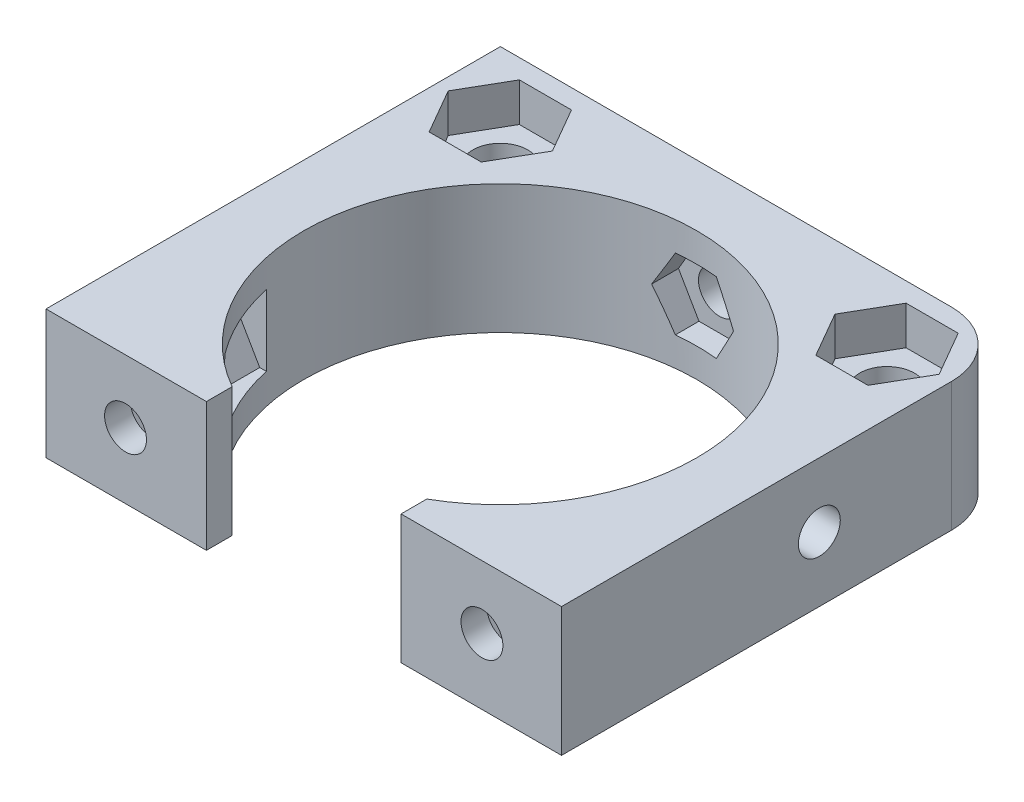
from build123d import *

# Parameters (mm, degrees)
CROQUIS1_R                              = 15.25
CROQUIS1_R_2                            = 2.125
SOPORTE_CAJA_REDUCTORA_DEPTH            = 20
CROQUIS3_R                              = 2.125
CORTAR_EXTRUIR1_DEPTH                   = 51.423828692
REDONDEO1_R                             = 5
BOSS_EXTRUDE1_DEPTH                     = 20
CUT_EXTRUDE1_REACH                      = 55.852
SKETCH2_R                               = 1.625
CUT_EXTRUDE2_DEPTH                      = 2
SKETCH4_R                               = 1.625
CUT_EXTRUDE3_DEPTH                      = 63.291652731
CUT_EXTRUDE4_START                      = -4.5
CUT_EXTRUDE4_DEPTH                      = 2
CROQUIS6_W                              = 4.75
CROQUIS6_H                              = 4.75
CORTAR_EXTRUIR17_DEPTH                  = 42.231056256
CROQUIS7_W                              = 60
CROQUIS7_H                              = 20
CORTAR_EXTRUIR18_DEPTH                  = 51.423828692
SALIENTE_EXTRUIR2_DEPTH                 = 49
SOPORTE_START                           = -15
SOPORTE_MOTOR_DEPTH                     = 15
CROQUIS12_R                             = 2.125
AGUJEROS_DE_SUJECION_A_BASE_DEPTH       = 84.087679592
TUERCA_START                            = -4
TUERCA_AGUJERO_DE_SUJECION_A_BASE_DEPTH = 10
SALIENTE_EXTRUIR4_DEPTH                 = 15
CORTAR_EXTRUIR19_DEPTH                  = 25
CROQUIS14_W                             = 50
CROQUIS14_H                             = 118
CORTAR_EXTRUIR22_DEPTH                  = 146.556045907
CROQUIS15_W                             = 10
CROQUIS15_H                             = 7
CORTAR_EXTRUIR23_DEPTH                  = 42.231056256
CORTAR_EXTRUIR24_DEPTH                  = 42.231056256
CROQUIS18_W                             = 40
CROQUIS18_H                             = 10
CORTAR_EXTRUIR25_DEPTH                  = 44.27311521
SALIENTE_EXTRUIR5_DEPTH                 = 10
CROQUIS20_R                             = 1
CORTAR_EXTRUIR26_DEPTH                  = 49.229270158
CORTAR_EXTRUIR27_REACH                  = 62.959
CORTAR_EXTRUIR27_END_RADIUS             = 15.25
CROQUIS21_R                             = 1.625
CROQUIS22_R                             = 2.125
CROQUIS22_R_2                           = 1
SALIENTE_EXTRUIR6_DEPTH                 = 10
CROQUIS23_R                             = 1.625
CORTAR_EXTRUIR28_DEPTH                  = 52.269508521
CORTAR_EXTRUIR29_START                  = -3
CORTAR_EXTRUIR29_DEPTH                  = 10
SALIENTE_EXTRUIR7_DEPTH                 = 10
CORTAR_EXTRUIR30_REACH                  = 72.235
CROQUIS27_R                             = 1.625
CORTAR_EXTRUIR31_REACH                  = 75.235
CORTAR_EXTRUIR31_START                  = -3
CORTAR_EXTRUIR32_REACH                  = 58.612
CROQUIS29_R                             = 1.625
CORTAR_EXTRUIR33_REACH                  = 61.112
CORTAR_EXTRUIR33_START                  = -2.5
CROQUIS35_W                             = 13.305418987
CROQUIS35_H                             = 6.826864192
CORTAR_EXTRUIR34_DEPTH                  = 63.931555098
CORTAR_EXTRUIR34_DEPTH_BACK             = 63.931555098
CORTAR_EXTRUIR35_START                  = -3
CORTAR_EXTRUIR35_DEPTH                  = 10
SALIENTE_EXTRUIR8_DEPTH                 = 10
SALIENTE_EXTRUIR9_DEPTH                 = 13
SALIENTE_EXTRUIR10_DEPTH                = 3
CROQUIS40_W                             = 106.583537839
CROQUIS40_H                             = 47.391515964
CORTAR_EXTRUIR36_DEPTH                  = 80.887064817
CORTAR_EXTRUIR36_DEPTH_BACK             = 80.887064817
CORTAR_EXTRUIR37_DEPTH                  = 67.2524009
CORTAR_EXTRUIR37_DEPTH_BACK             = 67.2524009
CORTAR_EXTRUIR38_DEPTH                  = 79.704784639
CORTAR_EXTRUIR38_DEPTH_BACK             = 79.704784639
SALIENTE_EXTRUIR11_DEPTH                = 10
CORTAR_EXTRUIR39_DEPTH                  = 63.9908649
CROQUIS45_W                             = 31.470301378
CROQUIS45_H                             = 10
CROQUIS45_R                             = 1.625
SALIENTE_EXTRUIR12_DEPTH                = 2.5
SALIENTE_EXTRUIR13_DEPTH                = 10
CORTAR_EXTRUIR40_START                  = -2
CROQUIS47_R                             = 1.625
CORTAR_EXTRUIR40_DEPTH                  = 10
CORTAR_EXTRUIR41_START                  = -12
CROQUIS48_R                             = 1.625
CORTAR_EXTRUIR41_DEPTH                  = 12
CORTAR_EXTRUIR42_DEPTH                  = 3
CROQUIS50_R                             = 2.125
CORTAR_EXTRUIR43_DEPTH                  = 52.795622989
CORTAR_EXTRUIR43_DEPTH_BACK             = 52.795622989
CORTAR_EXTRUIR44_DEPTH                  = 52.795622989
CORTAR_EXTRUIR44_DEPTH_BACK             = 52.795622989
SALIENTE_EXTRUIR14_DEPTH                = 10
CORTAR_EXTRUIR45_START                  = -24.591895
CORTAR_EXTRUIR45_DEPTH                  = 17.091895
CROQUIS55_W                             = 28.124395824
CROQUIS55_H                             = 43.73373215
CORTAR_EXTRUIR46_DEPTH                  = 42.681058385
CORTAR_EXTRUIR46_DEPTH_BACK             = 42.681058385


with BuildPart() as part:
    # Croquis1 → Soporte caja reductora (new body)
    with BuildSketch(Plane(origin=(0, 0, 0), x_dir=(1, 0, 0), z_dir=(0, 1, 0))):
        Polygon((-30, -15.25), (-20, -15.25), (-20, -20), (20, -20), (20, -15.25), (30, -15.25), (30, -7.25), (20, -4.25), (20, 20), (-20, 20), (-20, -4.25), (-30, -7.25), align=None)
        with Locations(Location((0, 0, 0), (0, 0, 270))):
            Circle(CROQUIS1_R, mode=Mode.SUBTRACT)
        with Locations(Location((-15, 15, 0), (0, 0, 270))):
            Circle(CROQUIS1_R_2, mode=Mode.SUBTRACT)
        with Locations(Location((15, 15, 0), (0, 0, 270))):
            Circle(CROQUIS1_R_2, mode=Mode.SUBTRACT)
    extrude(amount=-SOPORTE_CAJA_REDUCTORA_DEPTH)

    # Croquis3 → Cortar-Extruir1 (cut, through all)
    with BuildSketch(Plane.XY.offset(15.25)):
        with Locations((-23.5, -10)):
            Circle(CROQUIS3_R)
        with Locations((23.5, -10)):
            Circle(CROQUIS3_R)
    extrude(amount=-CORTAR_EXTRUIR1_DEPTH, mode=Mode.SUBTRACT)

    # Redondeo1
    redondeo1_edges = [part.edges().sort_by_distance(p)[0] for p in [
        (-20, -10, -20),
        (20, -10, -20),
    ]]
    fillet(redondeo1_edges, radius=REDONDEO1_R)

    # Sketch1 → Boss-Extrude1 (add)
    with BuildSketch(Plane(origin=(0, 0, 0), x_dir=(1, 0, 0), z_dir=(0, 1, 0))):
        with BuildLine():
            Line((25.5, 15), (20, 15))
            ThreePointArc((20, 15), (18.535533906, 18.535533906), (15, 20))
            Line((15, 20), (30, 20))
            Line((30, 20), (30, 8))
            Line((30, 8), (25.5, 8))
            Line((25.5, 8), (25.5, 15))
        make_face()
    extrude(amount=-BOSS_EXTRUDE1_DEPTH)

    # Sketch2 → Cut-Extrude1 (cut, up to next)
    with BuildSketch(Plane(origin=(0, 0, -20), x_dir=(-1, 0, 0), z_dir=(0, 0, -1)), mode=Mode.PRIVATE) as cut_extrude1_sk1:
        with Locations((-22.75, -10)):
            Circle(SKETCH2_R)
    cut_extrude1_tool1 = extrude(cut_extrude1_sk1.sketch, amount=-CUT_EXTRUDE1_REACH, mode=Mode.PRIVATE) & part.part
    add(cut_extrude1_tool1.solids().sort_by_distance((22.75, -10, -20))[0], mode=Mode.SUBTRACT)

    # Sketch3 → Cut-Extrude2 (cut)
    with BuildSketch(Plane.XY.offset(-15)):
        Polygon((20, -11.58771324), (22.75, -13.175426481), (25.5, -11.58771324), (25.5, -8.41228676), (22.75, -6.824573519), (20, -8.41228676), align=None)
    extrude(amount=-CUT_EXTRUDE2_DEPTH, mode=Mode.SUBTRACT)

    # Sketch4 → Cut-Extrude3 (cut, through all)
    with BuildSketch(Plane.ZY.offset(-25.5)):
        with Locations((-12.25, -10)):
            Circle(SKETCH4_R)
    extrude(amount=-CUT_EXTRUDE3_DEPTH, mode=Mode.SUBTRACT)

    # Sketch5 → Cut-Extrude4 (cut)
    with BuildSketch(Plane(origin=(30, 0, 0), x_dir=(0, 0, -1), z_dir=(1, 0, 0)).offset(CUT_EXTRUDE4_START)):
        Polygon((15, -11.58771324), (15, -8.41228676), (12.25, -6.824573519), (9.5, -8.41228676), (9.5, -11.58771324), (12.25, -13.175426481), align=None)
    extrude(amount=CUT_EXTRUDE4_DEPTH, mode=Mode.SUBTRACT)

    # Croquis6 → Cortar-Extruir17 (cut, through all)
    with BuildSketch(Plane(origin=(0, 0, 0), x_dir=(1, 0, 0), z_dir=(0, 1, 0))):
        Polygon((0, -15.25), (-15.25, -15.25), (-15.25, -20), (15.25, -20), (15.25, -15.25), align=None)
        with Locations((-17.625, -17.625)):
            Rectangle(CROQUIS6_W, CROQUIS6_H)
        with BuildLine():
            ThreePointArc((0, -15.25), (-10.783378413, -10.783378413), (-15.25, 0))
            Line((-15.25, 0), (-15.25, -15.25))
            Line((-15.25, -15.25), (0, -15.25))
        make_face()
        with BuildLine():
            Line((15.25, -15.25), (15.25, 0))
            ThreePointArc((15.25, 0), (10.783378413, -10.783378413), (0, -15.25))
            Line((0, -15.25), (15.25, -15.25))
        make_face()
        with Locations((17.625, -17.625)):
            Rectangle(CROQUIS6_W, CROQUIS6_H)
    extrude(amount=-CORTAR_EXTRUIR17_DEPTH, mode=Mode.SUBTRACT)


with BuildPart() as body_2:
    # Simetría1: mirrored copy
    add(part.part.mirror(Plane.ZX))

    # Croquis8 → Saliente-Extruir2 (add)
    with BuildSketch(Plane(origin=(0, 20, 0), x_dir=(1, 0, 0), z_dir=(0, 1, 0))):
        with BuildLine():
            Line((-12.664515522, 20), (-11.040489496, 13.939052358))
            Line((-11.040489496, 13.939052358), (-10.315162126, 11.232093763))
            ThreePointArc((-10.315162126, 11.232093763), (0, 15.25), (10.315162126, 11.232093763))
            Line((10.315162126, 11.232093763), (10.817418481, 13.87928066))
            Line((10.817418481, 13.87928066), (11.978715476, 20))
            Line((11.978715476, 20), (-12.664515522, 20))
        make_face()
    extrude(amount=SALIENTE_EXTRUIR2_DEPTH)

    # Croquis9 → Soporte motor (add)
    with BuildSketch(Plane(origin=(0, 69, 0), x_dir=(1, 0, 0), z_dir=(0, 1, 0)).offset(SOPORTE_START)):
        with BuildLine():
            Line((-20, 15), (-20, -4.25))
            Line((-20, -4.25), (-30, -7.25))
            Line((-30, -7.25), (-30, -15.25))
            Line((-30, -15.25), (0, -15.25))
            Line((0, -15.25), (0, -14.75))
            ThreePointArc((0, -14.75), (-10.429825023, 10.429825023), (14.75, 0))
            Line((14.75, 0), (20, 0))
            Line((20, 0), (20, 13.936837101))
            Line((20, 13.936837101), (12.664515522, 20))
            Line((12.664515522, 20), (-15, 20))
            ThreePointArc((-15, 20), (-18.535533906, 18.535533906), (-20, 15))
        make_face()
    extrude(amount=-SOPORTE_MOTOR_DEPTH)

    # Croquis12 → Agujeros de sujecion a base (cut, through all)
    with BuildSketch(Plane.XY.offset(15.25)):
        with Locations((-23.5, 46.5)):
            Circle(CROQUIS12_R)
    extrude(amount=-AGUJEROS_DE_SUJECION_A_BASE_DEPTH, mode=Mode.SUBTRACT)

    # Croquis13 → Tuerca Agujero de sujecion a base (cut)
    with BuildSketch(Plane.XY.offset(15.25).offset(TUERCA_START)):
        Polygon((-20, 44.479274058), (-20, 48.520725942), (-23.5, 50.541451884), (-27, 48.520725942), (-27, 44.479274058), (-23.5, 42.458548116), align=None)
    extrude(amount=-TUERCA_AGUJERO_DE_SUJECION_A_BASE_DEPTH, mode=Mode.SUBTRACT)

    # Croquis10 → Saliente-Extruir4 (add)
    with BuildSketch(Plane(origin=(0, 69, 0), x_dir=(1, 0, 0), z_dir=(0, 1, 0))):
        with BuildLine():
            ThreePointArc((10.315162126, 11.232093763), (0, 15.25), (-10.315162126, 11.232093763))
            Line((-10.315162126, 11.232093763), (-10.16850369, 10.684757026))
            ThreePointArc((-10.16850369, 10.684757026), (0, 14.75), (10.16850369, 10.684757026))
            Line((10.16850369, 10.684757026), (10.315162126, 11.232093763))
        make_face()
    extrude(amount=-SALIENTE_EXTRUIR4_DEPTH)

    # Croquis11 → Cortar-Extruir19 (cut)
    with BuildSketch(Plane.XZ):
        with BuildLine():
            Line((15.25, 4.25), (20, 4.25))
            Line((20, 4.25), (21.972856468, 4.84185694))
            ThreePointArc((21.972856468, 4.84185694), (19.948931102, 10.40625523), (16.543503257, 15.25))
            Line((16.543503257, 15.25), (15.25, 15.25))
            Line((15.25, 15.25), (15.25, 4.25))
        make_face()
        with BuildLine():
            Line((21.972856468, 4.84185694), (30, 7.25))
            Line((30, 7.25), (30, 15.25))
            Line((30, 15.25), (16.543503257, 15.25))
            ThreePointArc((16.543503257, 15.25), (19.948931102, 10.40625523), (21.972856468, 4.84185694))
        make_face()
        with BuildLine():
            ThreePointArc((20, -15), (18.535533906, -18.535533906), (15, -20))
            Line((15, -20), (30, -20))
            Line((30, -20), (30, -8))
            Line((30, -8), (25.5, -8))
            Line((25.5, -8), (25.5, -15))
            Line((25.5, -15), (20, -15))
        make_face()
    extrude(amount=-CORTAR_EXTRUIR19_DEPTH, mode=Mode.SUBTRACT)

    # Simetría2: body 2 across face


with BuildPart() as part_1:
    add(part.part)

    # Croquis7 → Cortar-Extruir18 (cut, through all)
    with BuildSketch(Plane(origin=(0, 0, -20), x_dir=(-1, 0, 0), z_dir=(0, 0, -1))):
        with Locations((0, -10)):
            Rectangle(CROQUIS7_W, CROQUIS7_H)
    extrude(amount=-CORTAR_EXTRUIR18_DEPTH, mode=Mode.SUBTRACT)


with BuildPart() as body_2_1:
    add(body_2.part)
    add(body_2.part.mirror(Plane(origin=(-0.229209569, 69, -16.663998028), x_dir=(0, 0, 1), z_dir=(0, 1, 0))))

    # Croquis14 → Cortar-Extruir22 (cut, through all)
    with BuildSketch(Plane.XY.offset(15.25)):
        with Locations((-5, 79)):
            Rectangle(CROQUIS14_W, CROQUIS14_H)
    extrude(amount=-CORTAR_EXTRUIR22_DEPTH, mode=Mode.SUBTRACT)

    # Croquis15 → Cortar-Extruir23 (cut, through all)
    with BuildSketch(Plane.XZ):
        with Locations((-25, 7.75)):
            Rectangle(CROQUIS15_W, CROQUIS15_H)
    extrude(amount=-CORTAR_EXTRUIR23_DEPTH, mode=Mode.SUBTRACT)

    # Croquis16 → Cortar-Extruir24 (cut, through all)
    with BuildSketch(Plane.XZ):
        Polygon((-30, 15.25), (-15.25, 15.25), (-15.25, 12.75), (-20, 12.75), (-20, 11.25), (-30, 11.25), (-30, 12.75), align=None)
    extrude(amount=-CORTAR_EXTRUIR24_DEPTH, mode=Mode.SUBTRACT)

    # Croquis18 → Cortar-Extruir25 (cut, through all)
    with BuildSketch(Plane(origin=(0, 0, -20), x_dir=(-1, 0, 0), z_dir=(0, 0, -1))):
        with Locations((0, 5)):
            Rectangle(CROQUIS18_W, CROQUIS18_H)
    extrude(amount=-CORTAR_EXTRUIR25_DEPTH, mode=Mode.SUBTRACT)

    # Croquis19 → Saliente-Extruir5 (add)
    with BuildSketch(Plane(origin=(0, 20, 0), x_dir=(1, 0, 0), z_dir=(0, 1, 0))):
        Polygon((-20, -12.75), (-34, -12.75), (-34, -7.75), (-24, -7.75), (-20, -3.75), align=None)
    extrude(amount=-SALIENTE_EXTRUIR5_DEPTH)

    # Croquis20 → Cortar-Extruir26 (cut, through all)
    with BuildSketch(Plane(origin=(0, 0, 7.75), x_dir=(-1, 0, 0), z_dir=(0, 0, -1))):
        with Locations((29, 15)):
            Circle(CROQUIS20_R)
    extrude(amount=-CORTAR_EXTRUIR26_DEPTH, mode=Mode.SUBTRACT)

    # Cortar-Extruir27: up to this cylinder (the profile starts outside it)
    cortar_extruir27_end = Plane(origin=(0, 15, 0), z_dir=(0, -1, 0)) * Cylinder(CORTAR_EXTRUIR27_END_RADIUS, 157.418, mode=Mode.PRIVATE)
    # Croquis21 → Cortar-Extruir27 (cut, up to the surface)
    with BuildSketch(Plane(origin=(20, 0, 0), x_dir=(0, 0, -1), z_dir=(1, 0, 0)), mode=Mode.PRIVATE) as cortar_extruir27_sk1:
        with Locations((4.75, 15)):
            Circle(CROQUIS21_R)
    cortar_extruir27_tool1 = extrude(cortar_extruir27_sk1.sketch, amount=-CORTAR_EXTRUIR27_REACH, mode=Mode.PRIVATE) - cortar_extruir27_end
    add(cortar_extruir27_tool1.solids().sort_by_distance((20, 15, -4.75))[0], mode=Mode.SUBTRACT)

    # Croquis22 → Saliente-Extruir6 (add)
    with BuildSketch(Plane.XZ.offset(-10)):
        with Locations((-15, -15)):
            Circle(CROQUIS22_R)
        with Locations(Location((-15, -15, 0), (0, 0, 270))):
            Circle(CROQUIS22_R_2, mode=Mode.SUBTRACT)
        with Locations((15, -15)):
            Circle(CROQUIS22_R)
        with Locations(Location((15, -15, 0), (0, 0, 270))):
            Circle(CROQUIS22_R_2, mode=Mode.SUBTRACT)
    extrude(amount=-SALIENTE_EXTRUIR6_DEPTH)

    # Croquis23 → Cortar-Extruir28 (cut, through all)
    with BuildSketch(Plane(origin=(0, 0, -20), x_dir=(-1, 0, 0), z_dir=(0, 0, -1))):
        with Locations((0, 15)):
            Circle(CROQUIS23_R)
    extrude(amount=-CORTAR_EXTRUIR28_DEPTH, mode=Mode.SUBTRACT)

    # Croquis24 → Cortar-Extruir29 (cut)
    with BuildSketch(Plane(origin=(0, 0, -20), x_dir=(-1, 0, 0), z_dir=(0, 0, -1)).offset(CORTAR_EXTRUIR29_START)):
        Polygon((1.58771324, 12.25), (3.175426481, 15), (1.58771324, 17.75), (-1.58771324, 17.75), (-3.175426481, 15), (-1.58771324, 12.25), align=None)
    extrude(amount=-CORTAR_EXTRUIR29_DEPTH, mode=Mode.SUBTRACT)

    # Croquis26 → Saliente-Extruir7 (add)
    with BuildSketch(Plane.XZ.offset(-10)):
        Polygon((-34, 7.75), (-34, 12.75), (-58.825, 12.75), (-39.160527763, -4.104491148), (-20, -4.104491148), (-20, -0.104491148), (-35.732113118, -0.104491148), (-29, 7.75), align=None)
        Polygon((-34.268209086, 7.75), (-39.594516123, 1.535690951), (-46.844874897, 7.75), align=None, mode=Mode.SUBTRACT)
    extrude(amount=-SALIENTE_EXTRUIR7_DEPTH)

    # Croquis27 → Cortar-Extruir30 (cut, up to next)
    with BuildSketch(Plane.XY.offset(12.75), mode=Mode.PRIVATE) as cortar_extruir30_sk1:
        with Locations((-40.544874897, 15)):
            Circle(CROQUIS27_R)
    cortar_extruir30_tool1 = extrude(cortar_extruir30_sk1.sketch, amount=-CORTAR_EXTRUIR30_REACH, mode=Mode.PRIVATE) & body_2_1.part
    # Croquis27 → Cortar-Extruir30 (cut, up to next)
    with BuildSketch(Plane.XY.offset(12.75), mode=Mode.PRIVATE) as cortar_extruir30_sk2:
        with Locations((-29, 15)):
            Circle(CROQUIS27_R)
    cortar_extruir30_tool2 = extrude(cortar_extruir30_sk2.sketch, amount=-CORTAR_EXTRUIR30_REACH, mode=Mode.PRIVATE) & body_2_1.part
    add(cortar_extruir30_tool1.solids().sort_by_distance((-40.544875, 15, 12.75))[0], mode=Mode.SUBTRACT)
    add(cortar_extruir30_tool2.solids().sort_by_distance((-29, 15, 12.75))[0], mode=Mode.SUBTRACT)

    # Croquis28 → Cortar-Extruir31 (cut, up to next)
    with BuildSketch(Plane.XY.offset(12.75).offset(CORTAR_EXTRUIR31_START), mode=Mode.PRIVATE) as cortar_extruir31_sk1:
        Polygon((-38.957161657, 12.25), (-37.369448416, 15), (-38.957161657, 17.75), (-42.132588137, 17.75), (-43.720301378, 15), (-42.132588137, 12.25), align=None)
    cortar_extruir31_tool1 = extrude(cortar_extruir31_sk1.sketch, amount=-CORTAR_EXTRUIR31_REACH, mode=Mode.PRIVATE) & body_2_1.part
    # Croquis28 → Cortar-Extruir31 (cut, up to next)
    with BuildSketch(Plane.XY.offset(12.75).offset(CORTAR_EXTRUIR31_START), mode=Mode.PRIVATE) as cortar_extruir31_sk2:
        Polygon((-27.41228676, 12.25), (-25.824573519, 15), (-27.41228676, 17.75), (-30.58771324, 17.75), (-32.175426481, 15), (-30.58771324, 12.25), align=None)
    cortar_extruir31_tool2 = extrude(cortar_extruir31_sk2.sketch, amount=-CORTAR_EXTRUIR31_REACH, mode=Mode.PRIVATE) & body_2_1.part
    add(cortar_extruir31_tool1.solids().sort_by_distance((-40.544875, 15, 9.75))[0], mode=Mode.SUBTRACT)
    add(cortar_extruir31_tool2.solids().sort_by_distance((-29, 15, 9.75))[0], mode=Mode.SUBTRACT)

    # Croquis29 → Cortar-Extruir32 (cut, up to next)
    with BuildSketch(Plane(origin=(-18.612848159, 0, -21.715982563), x_dir=(-0.7592713073348843, 0, 0.6507742172658468), z_dir=(-0.6507742172658468, 0, -0.7592713073348843)), mode=Mode.PRIVATE) as cortar_extruir32_sk1:
        with Locations((33.812368097, 15)):
            Circle(CROQUIS29_R)
    cortar_extruir32_tool1 = extrude(cortar_extruir32_sk1.sketch, amount=-CORTAR_EXTRUIR32_REACH, mode=Mode.PRIVATE) & body_2_1.part
    add(cortar_extruir32_tool1.solids().sort_by_distance((-44.285609, 15, 0.288235))[0], mode=Mode.SUBTRACT)

    # Croquis31 → Cortar-Extruir33 (cut, up to next)
    with BuildSketch(Plane(origin=(-18.612848159, 0, -21.715982563), x_dir=(-0.7592713073348843, 0, 0.6507742172658468), z_dir=(-0.6507742172658468, 0, -0.7592713073348843)).offset(CORTAR_EXTRUIR33_START), mode=Mode.PRIVATE) as cortar_extruir33_sk1:
        Polygon((36.562368097, 16.58771324), (33.812368097, 18.175426481), (31.062368097, 16.58771324), (31.062368097, 13.41228676), (33.812368097, 11.824573519), (36.562368097, 13.41228676), align=None)
    cortar_extruir33_tool1 = extrude(cortar_extruir33_sk1.sketch, amount=-CORTAR_EXTRUIR33_REACH, mode=Mode.PRIVATE) & body_2_1.part
    add(cortar_extruir33_tool1.solids().sort_by_distance((-42.658674, 15, 2.186413))[0], mode=Mode.SUBTRACT)

    # Croquis35 → Cortar-Extruir34 (cut, two sides)
    with BuildSketch(Plane(origin=(0, 20, 0), x_dir=(1, 0, 0), z_dir=(0, 1, 0))) as cortar_extruir34_sk:
        with Locations((17.04227466, -3.413432096)):
            Rectangle(CROQUIS35_W, CROQUIS35_H)
    extrude(amount=CORTAR_EXTRUIR34_DEPTH, mode=Mode.SUBTRACT)
    extrude(cortar_extruir34_sk.sketch, amount=-CORTAR_EXTRUIR34_DEPTH_BACK, mode=Mode.SUBTRACT)

    # Croquis36 → Cortar-Extruir35 (cut)
    with BuildSketch(Plane(origin=(20, 0, 0), x_dir=(0, 0, -1), z_dir=(1, 0, 0)).offset(CORTAR_EXTRUIR35_START)):
        Polygon((7.5, 16.58771324), (4.75, 18.175426481), (2, 16.58771324), (2, 13.41228676), (4.75, 11.824573519), (7.5, 13.41228676), align=None)
    extrude(amount=-CORTAR_EXTRUIR35_DEPTH, mode=Mode.SUBTRACT)

    # Croquis37 → Saliente-Extruir8 (add)
    with BuildSketch(Plane.XZ.offset(-10)):
        Polygon((-39.160527763, -4.104491148), (-20.614919368, -20), (-15, -20), (-19.558128305, -15.637570403), (-33.014002756, -4.104491148), align=None)
    extrude(amount=-SALIENTE_EXTRUIR8_DEPTH)

    # Croquis38 → Saliente-Extruir9 (add)
    with BuildSketch(Plane.XZ.offset(-10)):
        Polygon((-58.825, 12.75), (-38.825, 12.75), (-38.825, 9.75), (-55.324839942, 9.75), align=None)
    extrude(amount=SALIENTE_EXTRUIR9_DEPTH)

    # Croquis39 → Saliente-Extruir10 (add)
    with BuildSketch(Plane.XZ.offset(-10)):
        Polygon((-38.825, 9.75), (-38.825, 7.75), (-38.825, 5.75), (-50.657959865, 5.75), (-52.991399903, 7.75), (-55.324839942, 9.75), align=None)
    extrude(amount=SALIENTE_EXTRUIR10_DEPTH)

    # Simetría3: body 2 across face


with BuildPart() as body_2_2:
    add(body_2_1.part)
    add(body_2_1.part.mirror(Plane(origin=(-18.003999227, 20, -4.220503046), x_dir=(0, 0, 1), z_dir=(0, 1, 0))))

    # Croquis40 → Cortar-Extruir36 (cut, two sides)
    with BuildSketch(Plane(origin=(0, 0, -20), x_dir=(-1, 0, 0), z_dir=(0, 0, -1))) as cortar_extruir36_sk:
        with Locations((22.395502026, -3.695757982)):
            Rectangle(CROQUIS40_W, CROQUIS40_H)
    extrude(amount=CORTAR_EXTRUIR36_DEPTH, mode=Mode.SUBTRACT)
    extrude(cortar_extruir36_sk.sketch, amount=-CORTAR_EXTRUIR36_DEPTH_BACK, mode=Mode.SUBTRACT)

    # Croquis41 → Cortar-Extruir37 (cut, two sides)
    with BuildSketch(Plane.XZ.offset(-20)) as cortar_extruir37_sk:
        Polygon((-19.992980133, -22.302484261), (-20, 3.75), (-24, 7.75), (-56.035110209, 7.75), align=None)
    extrude(amount=CORTAR_EXTRUIR37_DEPTH, mode=Mode.SUBTRACT)
    extrude(cortar_extruir37_sk.sketch, amount=-CORTAR_EXTRUIR37_DEPTH_BACK, mode=Mode.SUBTRACT)

    # Croquis42 → Cortar-Extruir38 (cut, two sides)
    with BuildSketch(Plane(origin=(0, 0, 9.75), x_dir=(-1, 0, 0), z_dir=(0, 0, -1))) as cortar_extruir38_sk:
        Polygon((46.720301378, 20), (46.720301378, 30), (38.825, 30), (33.492952769, 43.760628779), (49.525340398, 48.951442806), (67.200390695, 42.512205152), (65.906601328, 20), (51.713995885, 13.864168239), align=None)
    extrude(amount=CORTAR_EXTRUIR38_DEPTH, mode=Mode.SUBTRACT)
    extrude(cortar_extruir38_sk.sketch, amount=-CORTAR_EXTRUIR38_DEPTH_BACK, mode=Mode.SUBTRACT)

    # Croquis43 → Saliente-Extruir11 (add)
    with BuildSketch(Plane.XZ.offset(-20)):
        Polygon((-19.993600539, -20), (-46.720301378, 7.75), (-43.839252857, 10.524807997), (-17.112552018, -17.225192003), align=None)
    extrude(amount=-SALIENTE_EXTRUIR11_DEPTH)

    # Croquis44 → Cortar-Extruir39 (cut, through all)
    with BuildSketch(Plane(origin=(0, 0, 9.75), x_dir=(-1, 0, 0), z_dir=(0, 0, -1))):
        Polygon((38.957161657, 27.75), (37.369448416, 25), (38.957161657, 22.25), (42.132588137, 22.25), (43.720301378, 25), (42.132588137, 27.75), align=None)
    extrude(amount=CORTAR_EXTRUIR39_DEPTH, mode=Mode.SUBTRACT)

    # Croquis45 → Saliente-Extruir12 (add)
    with BuildSketch(Plane.XY.offset(12.75)):
        with Locations((-30.985150689, 25)):
            Rectangle(CROQUIS45_W, CROQUIS45_H)
        with Locations((-40.544874897, 25)):
            Circle(CROQUIS45_R, mode=Mode.SUBTRACT)
        with Locations((-29, 25)):
            Circle(CROQUIS45_R, mode=Mode.SUBTRACT)
    extrude(amount=SALIENTE_EXTRUIR12_DEPTH)

    # Croquis46 → Saliente-Extruir13 (add)
    with BuildSketch(Plane.XZ.offset(-20)):
        with BuildLine():
            Line((15.25, 0), (20, 0))
            Line((20, 0), (20, 15.25))
            Line((20, 15.25), (7.549834435, 15.25))
            Line((7.549834435, 15.25), (7.549834435, 13.25))
            ThreePointArc((7.549834435, 13.25), (13.185171124, 7.662490615), (15.25, 0))
        make_face()
        with BuildLine():
            Line((-15.25, 0), (-15.25, 15.25))
            Line((-15.25, 15.25), (-7.549834435, 15.25))
            Line((-7.549834435, 15.25), (-7.549834435, 13.25))
            ThreePointArc((-7.549834435, 13.25), (-13.185171124, 7.662490615), (-15.25, 0))
        make_face()
    extrude(amount=-SALIENTE_EXTRUIR13_DEPTH)

    # Croquis47 → Cortar-Extruir40 (cut)
    with BuildSketch(Plane.XY.offset(15.25).offset(CORTAR_EXTRUIR40_START)):
        Polygon((15.41228676, 22.352505966), (17, 25.102505966), (15.41228676, 27.852505966), (12.236860279, 27.852505966), (10.649147039, 25.102505966), (12.236860279, 22.352505966), align=None)
        with Locations((13.824573519, 25.102505966)):
            Circle(CROQUIS47_R, mode=Mode.SUBTRACT)
        Polygon((-12.236860279, 22.352505966), (-15.41228676, 22.352505966), (-17, 25.102505966), (-15.41228676, 27.852505966), (-12.236860279, 27.852505966), (-10.649147039, 25.102505966), align=None)
        with Locations(Location((-13.824573519, 25.102505966, 0), (0, 0, 131.421584744))):
            Circle(CROQUIS47_R, mode=Mode.SUBTRACT)
    extrude(amount=-CORTAR_EXTRUIR40_DEPTH, mode=Mode.SUBTRACT)

    # Croquis48 → Cortar-Extruir41 (cut)
    with BuildSketch(Plane.XY.offset(15.25).offset(CORTAR_EXTRUIR41_START)):
        with Locations((13.824573519, 25.102505966)):
            Circle(CROQUIS48_R)
        with Locations((-13.824573519, 25.102505966)):
            Circle(CROQUIS48_R)
    extrude(amount=CORTAR_EXTRUIR41_DEPTH, mode=Mode.SUBTRACT)

    # Croquis49 → Cortar-Extruir42 (cut)
    with BuildSketch(Plane(origin=(0, 30, 0), x_dir=(1, 0, 0), z_dir=(0, 1, 0))):
        Polygon((-12.979274058, 11.5), (-10.958548116, 15), (-12.979274058, 18.5), (-17.020725942, 18.5), (-19.041451884, 15), (-17.020725942, 11.5), align=None)
        Polygon((17.020725942, 11.5), (19.041451884, 15), (17.020725942, 18.5), (12.979274058, 18.5), (10.958548116, 15), (12.979274058, 11.5), align=None)
    extrude(amount=-CORTAR_EXTRUIR42_DEPTH, mode=Mode.SUBTRACT)

    # Croquis50 → Cortar-Extruir43 (cut, two sides)
    with BuildSketch(Plane(origin=(0, 30, 0), x_dir=(1, 0, 0), z_dir=(0, 1, 0))) as cortar_extruir43_sk:
        with Locations(Location((-15, 15, 0), (0, 0, 270))):
            Circle(CROQUIS50_R)
        with Locations(Location((15, 15, 0), (0, 0, 270))):
            Circle(CROQUIS50_R)
    extrude(amount=CORTAR_EXTRUIR43_DEPTH, mode=Mode.SUBTRACT)
    extrude(cortar_extruir43_sk.sketch, amount=-CORTAR_EXTRUIR43_DEPTH_BACK, mode=Mode.SUBTRACT)

    # Croquis51 → Cortar-Extruir44 (cut, two sides)
    with BuildSketch(Plane(origin=(0, 30, 0), x_dir=(1, 0, 0), z_dir=(0, 1, 0))) as cortar_extruir44_sk:
        Polygon((-35.175426481, -15.25), (-35.175426481, -7.75), (-19.995154673, 14.232221634), (-19.993600539, 20), (-53.730413568, 5.241110817), (-52.418444784, -16.738442517), align=None)
    extrude(amount=CORTAR_EXTRUIR44_DEPTH, mode=Mode.SUBTRACT)
    extrude(cortar_extruir44_sk.sketch, amount=-CORTAR_EXTRUIR44_DEPTH_BACK, mode=Mode.SUBTRACT)

    # Croquis52 → Saliente-Extruir14 (add)
    with BuildSketch(Plane(origin=(0, 30, 0), x_dir=(1, 0, 0), z_dir=(0, 1, 0))):
        Polygon((-35.175426481, -7.75), (-19.993600539, 20), (-20, -3.75), (-24, -7.75), align=None)
    extrude(amount=-SALIENTE_EXTRUIR14_DEPTH)

    # Croquis54 → Cortar-Extruir45 (cut)
    with BuildSketch(Plane.XY.offset(15.25).offset(CORTAR_EXTRUIR45_START)):
        Polygon((-25.824573519, 25), (-27.41228676, 27.75), (-30.58771324, 27.75), (-32.175426481, 25), (-30.58771324, 22.25), (-27.41228676, 22.25), align=None)
    extrude(amount=CORTAR_EXTRUIR45_DEPTH, mode=Mode.SUBTRACT)

    # Croquis55 → Cortar-Extruir46 (cut, two sides)
    with BuildSketch(Plane(origin=(0, 30, 0), x_dir=(1, 0, 0), z_dir=(0, 1, 0))) as cortar_extruir46_sk:
        with Locations((-34.055798451, -1.866866075)):
            Rectangle(CROQUIS55_W, CROQUIS55_H)
    extrude(amount=CORTAR_EXTRUIR46_DEPTH, mode=Mode.SUBTRACT)
    extrude(cortar_extruir46_sk.sketch, amount=-CORTAR_EXTRUIR46_DEPTH_BACK, mode=Mode.SUBTRACT)


solid = body_2_2.part
